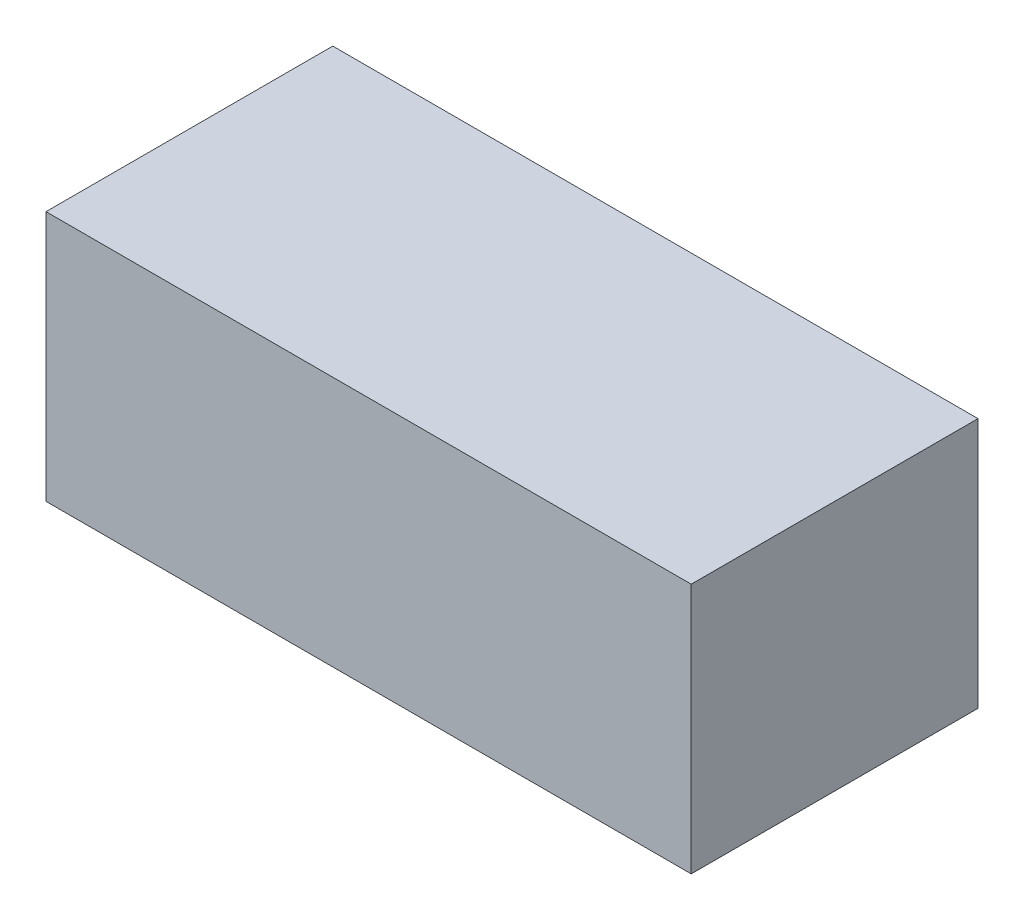
from build123d import *

# Parameters (mm, degrees)
SKETCH_1_W      = 180
SKETCH_1_H      = 70
EXTRUDE_1_DEPTH = 80


with BuildPart() as part:
    # 草圖1 → 填料-伸長1 (new body)
    with BuildSketch(Plane.XY):
        with Locations((21.817712619, -12.793103448)):
            Rectangle(SKETCH_1_W, SKETCH_1_H)
    extrude(amount=EXTRUDE_1_DEPTH)


solid = part.part
